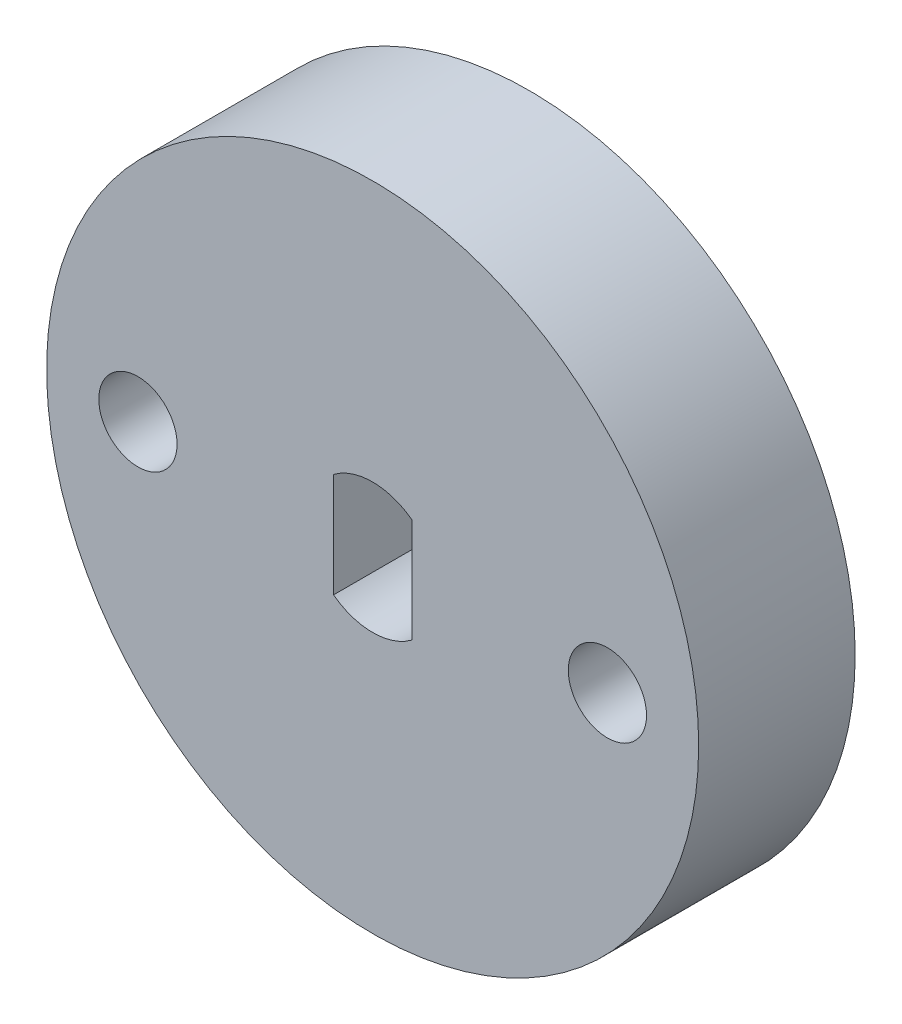
from build123d import *

# Parameters (mm, degrees)
SKETCH1_R           = 12.5
SKETCH1_R_2         = 1.5
BOSS_EXTRUDE1_DEPTH = 6


with BuildPart() as part:
    # Sketch1 → Boss-Extrude1 (new body)
    with BuildSketch(Plane.XY):
        Circle(SKETCH1_R)
        with BuildLine():
            Line((-1.5, -2), (-1.5, 2))
            ThreePointArc((-1.5, 2), (0, 2.5), (1.5, 2))
            Line((1.5, 2), (1.5, -2))
            ThreePointArc((1.5, -2), (0, -2.5), (-1.5, -2))
        make_face(mode=Mode.SUBTRACT)
        with Locations((-9, 0)):
            Circle(SKETCH1_R_2, mode=Mode.SUBTRACT)
        with Locations((9, 0)):
            Circle(SKETCH1_R_2, mode=Mode.SUBTRACT)
    extrude(amount=BOSS_EXTRUDE1_DEPTH)


solid = part.part
